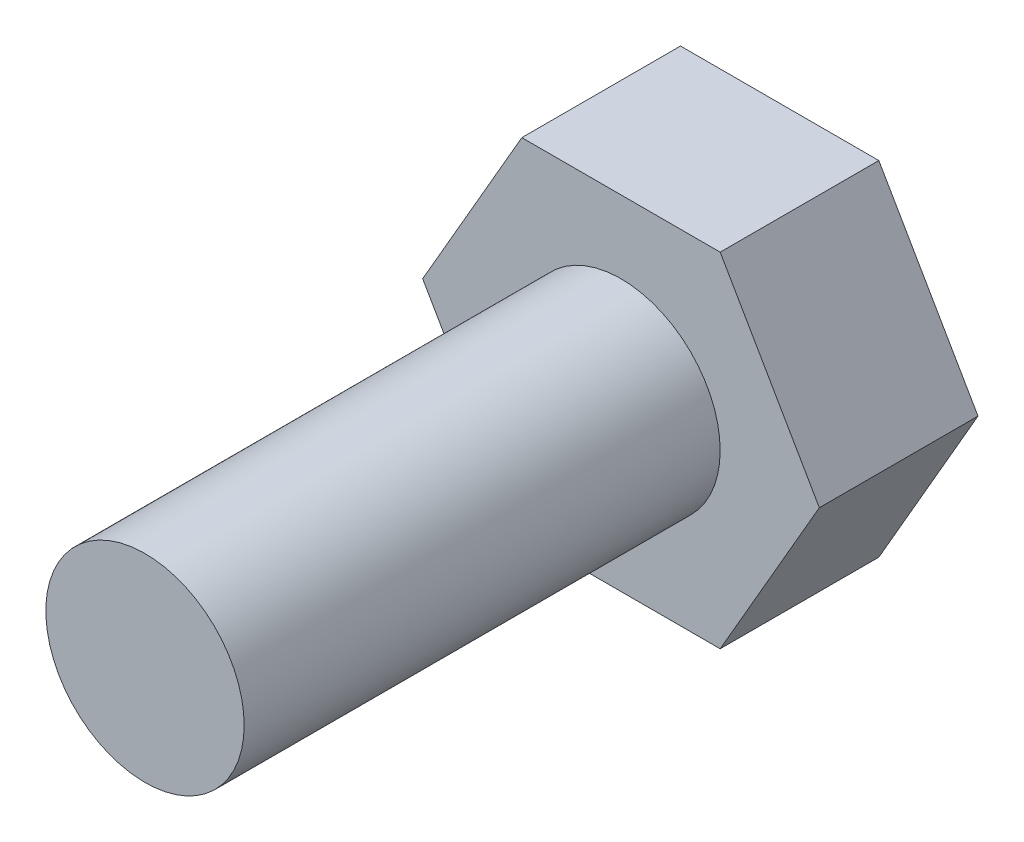
from build123d import *

# Parameters (mm, degrees)
CROQUIS2_R              = 2.5
SALIENTE_EXTRUIR1_DEPTH = 12
SALIENTE_EXTRUIR3_DEPTH = 4


with BuildPart() as part:
    # Croquis2 → Saliente-Extruir1 (new body)
    with BuildSketch(Plane.XY):
        Circle(CROQUIS2_R)
    extrude(amount=SALIENTE_EXTRUIR1_DEPTH)

    # Croquis3 → Saliente-Extruir3 (add)
    with BuildSketch(Plane(origin=(0, 0, 0), x_dir=(-1, 0, 0), z_dir=(0, 0, -1))):
        Polygon((5, 0), (2.5, 4.330127019), (-2.5, 4.330127019), (-5, 0), (-2.5, -4.330127019), (2.5, -4.330127019), align=None)
    extrude(amount=SALIENTE_EXTRUIR3_DEPTH)


solid = part.part
